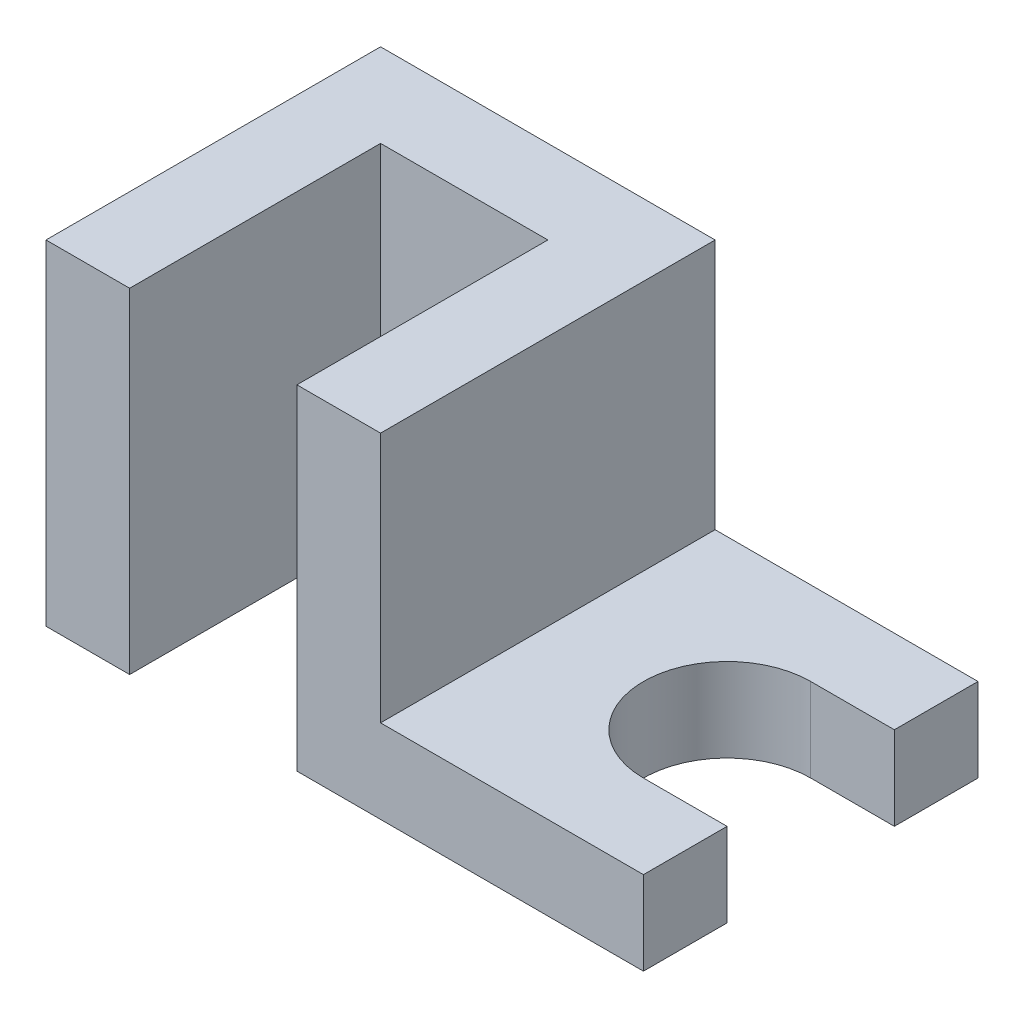
from build123d import *

# Parameters (mm, degrees)
EXTRUDE_1_DEPTH     = 28
SKETCH_2_W          = 22
SKETCH_2_H          = 21
CUT_EXTRUDE_1_DEPTH = 29


with BuildPart() as part:
    # 스케치1 → 보스-돌출1 (new body)
    with BuildSketch(Plane(origin=(0, 0, 0), x_dir=(1, 0, 0), z_dir=(0, 1, 0))):
        with BuildLine():
            Line((7, 0), (7, 21))
            Line((7, 21), (21, 21))
            Line((21, 21), (21, 0))
            Line((21, 0), (50, 0))
            Line((50, 0), (50, 7))
            Line((50, 7), (43, 7))
            ThreePointArc((43, 7), (36, 14), (43, 21))
            Line((43, 21), (50, 21))
            Line((50, 21), (50, 28))
            Line((50, 28), (0, 28))
            Line((0, 28), (0, 0))
            Line((0, 0), (7, 0))
        make_face()
    extrude(amount=EXTRUDE_1_DEPTH)

    # 스케치2 → 컷-돌출1 (cut, through all)
    with BuildSketch(Plane.XY):
        with Locations((39, 17.5)):
            Rectangle(SKETCH_2_W, SKETCH_2_H)
    extrude(amount=-CUT_EXTRUDE_1_DEPTH, mode=Mode.SUBTRACT)


solid = part.part
